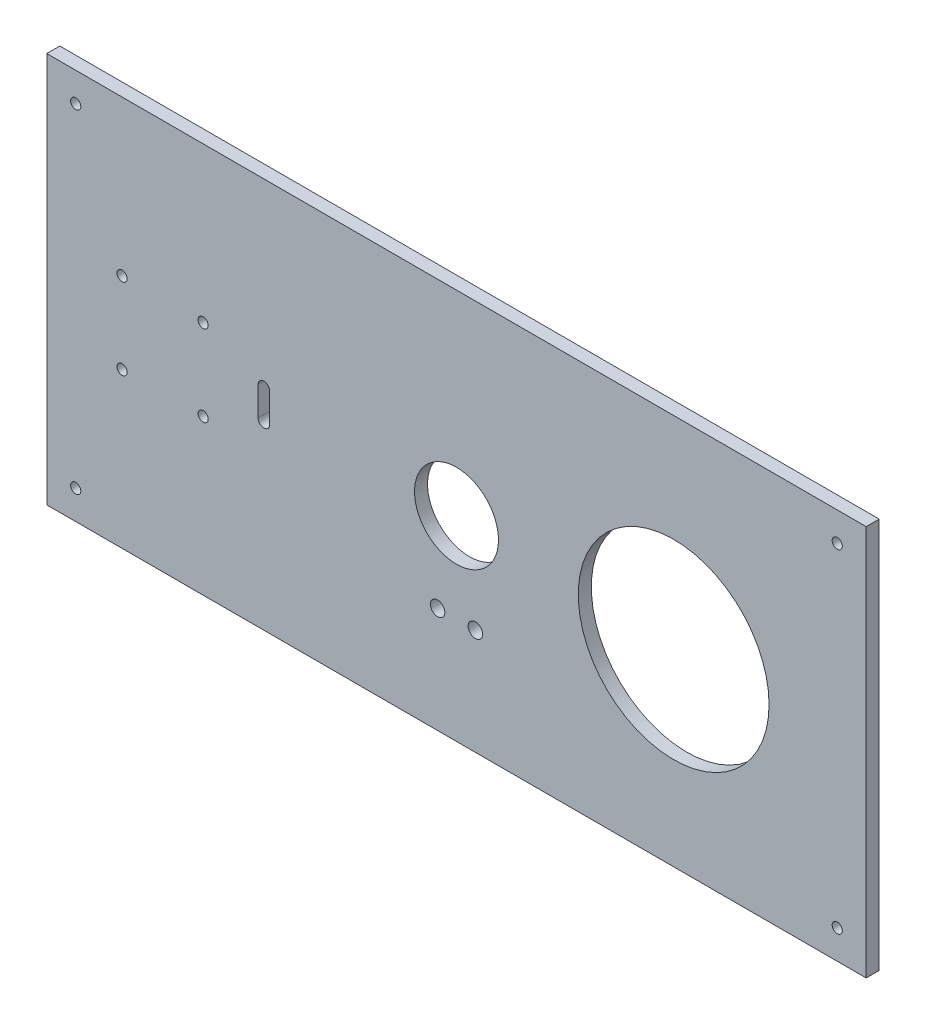
from build123d import *

# Parameters (mm, degrees)
SKETCH1_W               = 283
SKETCH1_H               = 135
BOSS_EXTRUDE1_DEPTH     = 4.5
CUT_EXTRUDE1_REACH      = 158.84
SKETCH1_3_R             = 1.75
MIRROR3_COPY_1_REACH    = 158.84
MIRROR3_COPY_1_SKETCH_R = 1.75
MIRROR3_COPY_2_REACH    = 158.84
MIRROR3_COPY_2_SKETCH_R = 1.75
CUT_EXTRUDE2_REACH      = 158.84
SKETCH2_R               = 1.75
CUT_EXTRUDE3_REACH      = 158.84
SKETCH3_R               = 32.95
SKETCH3_R_2             = 14.5
SKETCH3_R_3             = 2.5


with BuildPart() as part:
    # Sketch1 → Boss-Extrude1 (new body)
    with BuildSketch(Plane.XY):
        Rectangle(SKETCH1_W, SKETCH1_H)
    extrude(amount=BOSS_EXTRUDE1_DEPTH)

    # Sketch1_3 → Cut-Extrude1 (cut, up to next)
    with BuildSketch(Plane.XY, mode=Mode.PRIVATE) as cut_extrude1_sk1:
        with Locations((-131.5, 57.5)):
            Circle(SKETCH1_3_R)
    cut_extrude1_tool1 = extrude(cut_extrude1_sk1.sketch, amount=CUT_EXTRUDE1_REACH, mode=Mode.PRIVATE) & part.part
    cut_extrude1 = cut_extrude1_tool1.solids().sort_by_distance((-131.5, 57.5, 0))[0]
    add(cut_extrude1, mode=Mode.SUBTRACT)

    # Mirror2: Cut-Extrude1 across plane
    add(cut_extrude1.mirror(Plane.ZX), mode=Mode.SUBTRACT)

    # Mirror3 copy 1 sketch → Mirror3 copy 1 (cut, up to next)
    with BuildSketch(Plane(origin=(0, 0, 0), x_dir=(-1, 0, 0), z_dir=(0, 0, 1)), mode=Mode.PRIVATE) as mirror3_copy_1_sk1:
        with Locations((-131.5, 57.5)):
            Circle(MIRROR3_COPY_1_SKETCH_R)
    mirror3_copy_1_tool1 = extrude(mirror3_copy_1_sk1.sketch, amount=MIRROR3_COPY_1_REACH, mode=Mode.PRIVATE) & part.part
    add(mirror3_copy_1_tool1.solids().sort_by_distance((131.5, -57.5, 0))[0], mode=Mode.SUBTRACT)

    # Mirror3 copy 2 sketch → Mirror3 copy 2 (cut, up to next)
    with BuildSketch(Plane(origin=(0, 0, 0), x_dir=(-1, 0, 0), z_dir=(0, 0, 1)), mode=Mode.PRIVATE) as mirror3_copy_2_sk1:
        with Locations((-131.5, -57.5)):
            Circle(MIRROR3_COPY_2_SKETCH_R)
    mirror3_copy_2_tool1 = extrude(mirror3_copy_2_sk1.sketch, amount=MIRROR3_COPY_2_REACH, mode=Mode.PRIVATE) & part.part
    add(mirror3_copy_2_tool1.solids().sort_by_distance((131.5, 57.5, 0))[0], mode=Mode.SUBTRACT)

    # Sketch2 → Cut-Extrude2 (cut, up to next)
    with BuildSketch(Plane.XY.offset(4.5), mode=Mode.PRIVATE) as cut_extrude2_sk1:
        with Locations((-87.5, -14)):
            Circle(SKETCH2_R)
    cut_extrude2_tool1 = extrude(cut_extrude2_sk1.sketch, amount=-CUT_EXTRUDE2_REACH, mode=Mode.PRIVATE) & part.part
    # Sketch2 → Cut-Extrude2 (cut, up to next)
    with BuildSketch(Plane.XY.offset(4.5), mode=Mode.PRIVATE) as cut_extrude2_sk2:
        with Locations((-115.5, -14)):
            Circle(SKETCH2_R)
    cut_extrude2_tool2 = extrude(cut_extrude2_sk2.sketch, amount=-CUT_EXTRUDE2_REACH, mode=Mode.PRIVATE) & part.part
    # Sketch2 → Cut-Extrude2 (cut, up to next)
    with BuildSketch(Plane.XY.offset(4.5), mode=Mode.PRIVATE) as cut_extrude2_sk3:
        with Locations((-115.5, 14)):
            Circle(SKETCH2_R)
    cut_extrude2_tool3 = extrude(cut_extrude2_sk3.sketch, amount=-CUT_EXTRUDE2_REACH, mode=Mode.PRIVATE) & part.part
    # Sketch2 → Cut-Extrude2 (cut, up to next)
    with BuildSketch(Plane.XY.offset(4.5), mode=Mode.PRIVATE) as cut_extrude2_sk4:
        with Locations((-87.5, 14)):
            Circle(SKETCH2_R)
    cut_extrude2_tool4 = extrude(cut_extrude2_sk4.sketch, amount=-CUT_EXTRUDE2_REACH, mode=Mode.PRIVATE) & part.part
    # Sketch2 → Cut-Extrude2 (cut, up to next)
    with BuildSketch(Plane.XY.offset(4.5), mode=Mode.PRIVATE) as cut_extrude2_sk5:
        with BuildLine():
            Line((-68.5, -5), (-68.5, 5))
            ThreePointArc((-68.5, 5), (-66.5, 7), (-64.5, 5))
            Line((-64.5, 5), (-64.5, -5))
            ThreePointArc((-64.5, -5), (-66.5, -7), (-68.5, -5))
        make_face()
    cut_extrude2_tool5 = extrude(cut_extrude2_sk5.sketch, amount=-CUT_EXTRUDE2_REACH, mode=Mode.PRIVATE) & part.part
    add(cut_extrude2_tool1.solids().sort_by_distance((-87.5, -14, 4.5))[0], mode=Mode.SUBTRACT)
    add(cut_extrude2_tool2.solids().sort_by_distance((-115.5, -14, 4.5))[0], mode=Mode.SUBTRACT)
    add(cut_extrude2_tool3.solids().sort_by_distance((-115.5, 14, 4.5))[0], mode=Mode.SUBTRACT)
    add(cut_extrude2_tool4.solids().sort_by_distance((-87.5, 14, 4.5))[0], mode=Mode.SUBTRACT)
    add(cut_extrude2_tool5.solids().sort_by_distance((-66.5, 0, 4.5))[0], mode=Mode.SUBTRACT)

    # Sketch3 → Cut-Extrude3 (cut, up to next)
    with BuildSketch(Plane.XY.offset(4.5), mode=Mode.PRIVATE) as cut_extrude3_sk1:
        with Locations((75, -2.5)):
            Circle(SKETCH3_R)
    cut_extrude3_tool1 = extrude(cut_extrude3_sk1.sketch, amount=-CUT_EXTRUDE3_REACH, mode=Mode.PRIVATE) & part.part
    # Sketch3 → Cut-Extrude3 (cut, up to next)
    with BuildSketch(Plane.XY.offset(4.5), mode=Mode.PRIVATE) as cut_extrude3_sk2:
        Circle(SKETCH3_R_2)
    cut_extrude3_tool2 = extrude(cut_extrude3_sk2.sketch, amount=-CUT_EXTRUDE3_REACH, mode=Mode.PRIVATE) & part.part
    # Sketch3 → Cut-Extrude3 (cut, up to next)
    with BuildSketch(Plane.XY.offset(4.5), mode=Mode.PRIVATE) as cut_extrude3_sk3:
        with Locations((-6.525, -30.95)):
            Circle(SKETCH3_R_3)
    cut_extrude3_tool3 = extrude(cut_extrude3_sk3.sketch, amount=-CUT_EXTRUDE3_REACH, mode=Mode.PRIVATE) & part.part
    # Sketch3 → Cut-Extrude3 (cut, up to next)
    with BuildSketch(Plane.XY.offset(4.5), mode=Mode.PRIVATE) as cut_extrude3_sk4:
        with Locations((6.525, -30.95)):
            Circle(SKETCH3_R_3)
    cut_extrude3_tool4 = extrude(cut_extrude3_sk4.sketch, amount=-CUT_EXTRUDE3_REACH, mode=Mode.PRIVATE) & part.part
    add(cut_extrude3_tool1.solids().sort_by_distance((75, -2.5, 4.5))[0], mode=Mode.SUBTRACT)
    add(cut_extrude3_tool2.solids().sort_by_distance((0, 0, 4.5))[0], mode=Mode.SUBTRACT)
    add(cut_extrude3_tool3.solids().sort_by_distance((-6.525, -30.95, 4.5))[0], mode=Mode.SUBTRACT)
    add(cut_extrude3_tool4.solids().sort_by_distance((6.525, -30.95, 4.5))[0], mode=Mode.SUBTRACT)


solid = part.part
